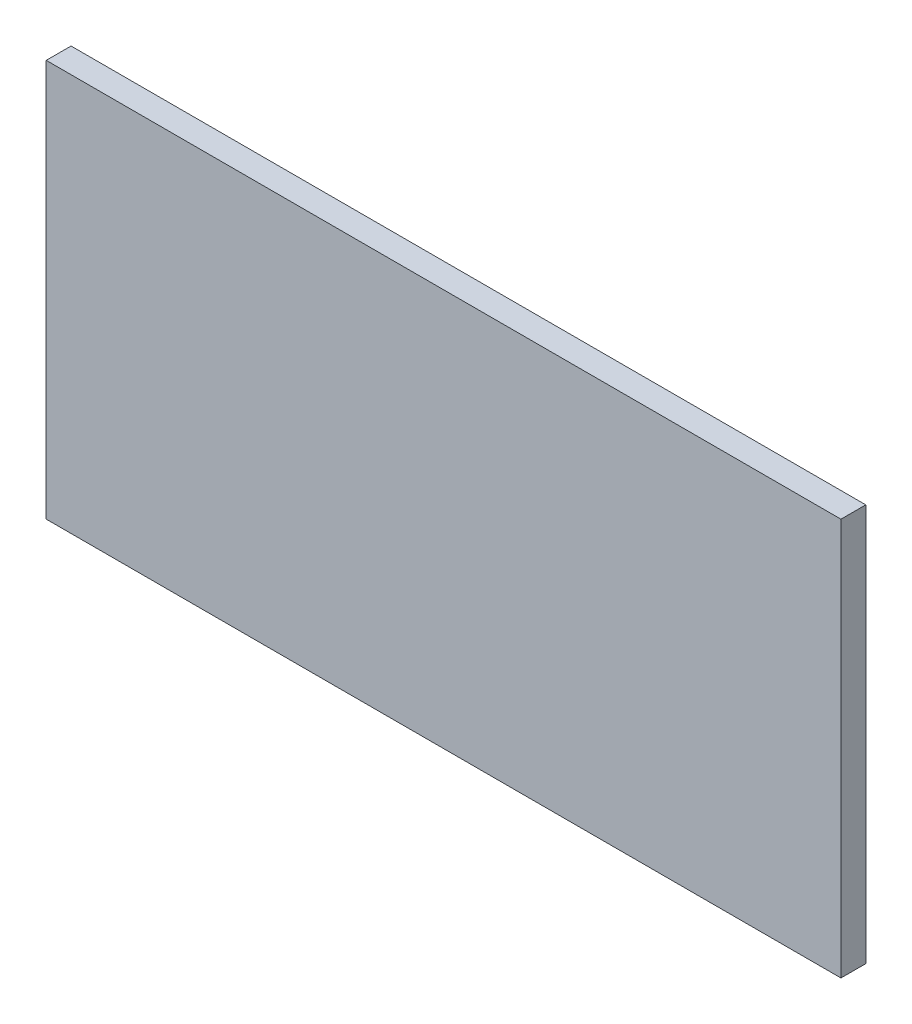
from build123d import *

# Parameters (mm, degrees)
SKETCH1_W           = 101.6
SKETCH1_H           = 50.8
BOSS_EXTRUDE1_DEPTH = 3.175


with BuildPart() as part:
    # Sketch1 → Boss-Extrude1 (new body)
    with BuildSketch(Plane.XY):
        Rectangle(SKETCH1_W, SKETCH1_H)
    extrude(amount=BOSS_EXTRUDE1_DEPTH)


solid = part.part
